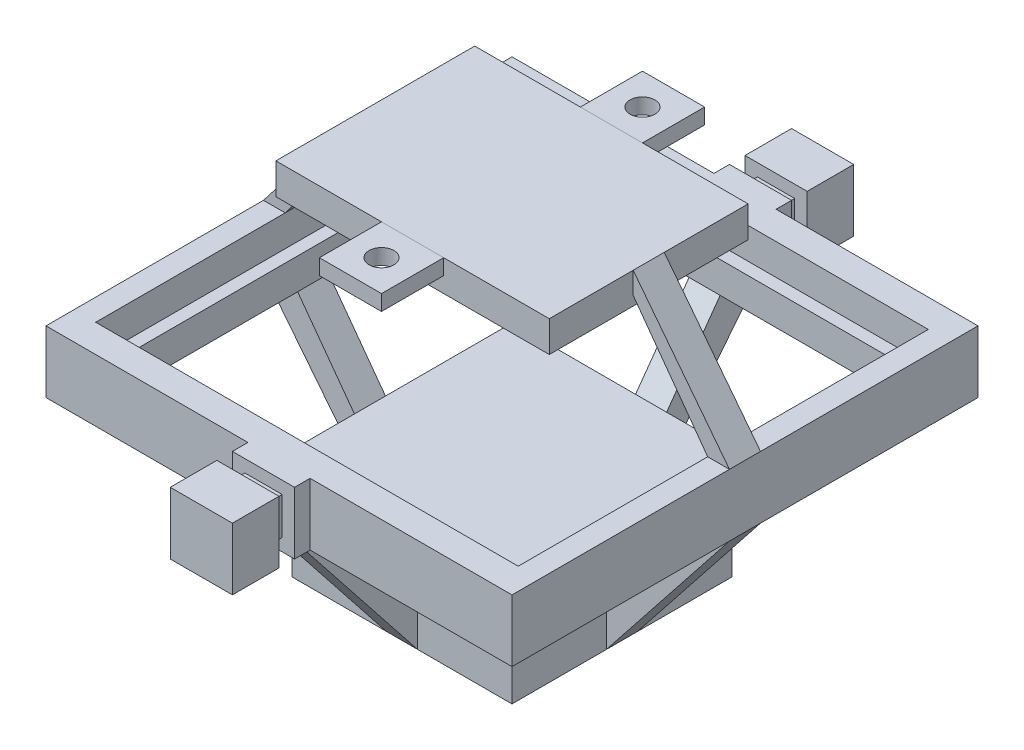
from build123d import *

# Parameters (mm, degrees)
SKETCH2_W              = 75
SKETCH2_H              = 75
BOSS_EXTRUDE1_DEPTH    = 5
SKETCH2_2_W            = 75
SKETCH2_2_H            = 75
BOSS_EXTRUDE2_DEPTH    = 5
SKETCH4_W              = 68
SKETCH4_H              = 66
CUT_EXTRUDE1_DEPTH     = 5
SKETCH5_W              = 64
SKETCH5_H              = 62
CUT_EXTRUDE2_DEPTH     = 5
SKETCH6_W              = 10
SKETCH6_H              = 10
BOSS_EXTRUDE3_DEPTH    = 2.5
SKETCH7_W              = 6
SKETCH7_H              = 6
BOSS_EXTRUDE4_DEPTH    = 2.5
SKETCH8_W              = 10
SKETCH8_H              = 10
BOSS_EXTRUDE5_DEPTH    = 7.5
SKETCH9_W              = 10
SKETCH9_H              = 10
BOSS_EXTRUDE6_DEPTH    = 2.5
SKETCH10_W             = 6
SKETCH10_H             = 6
BOSS_EXTRUDE7_DEPTH    = 2.5
SKETCH11_W             = 10
SKETCH11_H             = 10
BOSS_EXTRUDE8_DEPTH    = 7.5
SKETCH12_W             = 35.4
SKETCH12_H             = 35.4
BOSS_EXTRUDE9_DEPTH    = 17.7
SKETCH13_W             = 25.4
SKETCH13_H             = 25.4
CUT_EXTRUDE3_DEPTH     = 12.7
SKETCH14_W             = 44
SKETCH14_H             = 32
BOSS_EXTRUDE10_DEPTH   = 5
BOSS_EXTRUDE11_DEPTH   = 2.5
BOSS_EXTRUDE12_DEPTH   = 2.5
BOSS_EXTRUDE13_DEPTH   = 2.5
BOSS_EXTRUDE14_DEPTH   = 2.5
BOSS_EXTRUDE21_DEPTH   = 2.5
BOSS_EXTRUDE22_DEPTH   = 2.5
BOSS_EXTRUDE23_DEPTH   = 2.5
BOSS_EXTRUDE24_DEPTH   = 2.5
SKETCH22_W             = 10
SKETCH22_H             = 10
BOSS_EXTRUDE25_DEPTH   = 2.5
BOSS_EXTRUDE25_2_DEPTH = 2.5
SKETCH23_R             = 2
CUT_EXTRUDE4_DEPTH     = 2.5


with BuildPart() as part:
    # Sketch2 → Boss-Extrude1 (new body)
    with BuildSketch(Plane(origin=(0, 0, 0), x_dir=(1, 0, 0), z_dir=(0, 1, 0))):
        Rectangle(SKETCH2_W, SKETCH2_H)
    extrude(amount=BOSS_EXTRUDE1_DEPTH)

    # Sketch2_2 → Boss-Extrude2 (add)
    with BuildSketch(Plane(origin=(0, 0, 0), x_dir=(1, 0, 0), z_dir=(0, 1, 0))):
        Rectangle(SKETCH2_2_W, SKETCH2_2_H)
    extrude(amount=-BOSS_EXTRUDE2_DEPTH)

    # Sketch4 → Cut-Extrude1 (cut)
    with BuildSketch(Plane(origin=(0, 5, 0), x_dir=(1, 0, 0), z_dir=(0, 1, 0))):
        Rectangle(SKETCH4_W, SKETCH4_H)
    extrude(amount=-CUT_EXTRUDE1_DEPTH, mode=Mode.SUBTRACT)

    # Sketch5 → Cut-Extrude2 (cut)
    with BuildSketch(Plane(origin=(0, 0, 0), x_dir=(1, 0, 0), z_dir=(0, 1, 0))):
        Rectangle(SKETCH5_W, SKETCH5_H)
    extrude(amount=-CUT_EXTRUDE2_DEPTH, mode=Mode.SUBTRACT)

    # Sketch6 → Boss-Extrude3 (add)
    with BuildSketch(Plane.XY.offset(37.5)):
        Rectangle(SKETCH6_W, SKETCH6_H)
    extrude(amount=BOSS_EXTRUDE3_DEPTH)

    # Sketch7 → Boss-Extrude4 (add)
    with BuildSketch(Plane.XY.offset(40)):
        Rectangle(SKETCH7_W, SKETCH7_H)
    extrude(amount=BOSS_EXTRUDE4_DEPTH)

    # Sketch8 → Boss-Extrude5 (add)
    with BuildSketch(Plane.XY.offset(42.5)):
        Rectangle(SKETCH8_W, SKETCH8_H)
    extrude(amount=BOSS_EXTRUDE5_DEPTH)

    # Sketch9 → Boss-Extrude6 (add)
    with BuildSketch(Plane(origin=(0, 0, -37.5), x_dir=(-1, 0, 0), z_dir=(0, 0, -1))):
        Rectangle(SKETCH9_W, SKETCH9_H)
    extrude(amount=BOSS_EXTRUDE6_DEPTH)

    # Sketch10 → Boss-Extrude7 (add)
    with BuildSketch(Plane(origin=(0, 0, -40), x_dir=(-1, 0, 0), z_dir=(0, 0, -1))):
        Rectangle(SKETCH10_W, SKETCH10_H)
    extrude(amount=BOSS_EXTRUDE7_DEPTH)

    # Sketch11 → Boss-Extrude8 (add)
    with BuildSketch(Plane(origin=(0, 0, -42.5), x_dir=(-1, 0, 0), z_dir=(0, 0, -1))):
        Rectangle(SKETCH11_W, SKETCH11_H)
    extrude(amount=BOSS_EXTRUDE8_DEPTH)



with BuildPart() as body_2:
    # Sketch12 → Boss-Extrude9 (new body)
    with BuildSketch(Plane(origin=(0, -30, 0), x_dir=(1, 0, 0), z_dir=(0, 1, 0))):
        Rectangle(SKETCH12_W, SKETCH12_H)
    extrude(amount=BOSS_EXTRUDE9_DEPTH)

    # Sketch13 → Cut-Extrude3 (cut)
    with BuildSketch(Plane.XZ.offset(30)):
        Rectangle(SKETCH13_W, SKETCH13_H)
    extrude(amount=-CUT_EXTRUDE3_DEPTH, mode=Mode.SUBTRACT)


with BuildPart() as body_3:
    # Sketch14 → Boss-Extrude10 (new body)
    with BuildSketch(Plane(origin=(0, 25, 0), x_dir=(1, 0, 0), z_dir=(0, 1, 0))):
        Rectangle(SKETCH14_W, SKETCH14_H)
    extrude(amount=-BOSS_EXTRUDE10_DEPTH)


with BuildPart() as part_1:
    add(part.part)

    add(body_2.part)  # Boss-Extrude11 merges body 2
    # Sketch15 → Boss-Extrude11 (add)
    with BuildSketch(Plane.XY):
        Polygon((17.7, -30), (37.5, -5), (32, -5), (17.7, -24.5), align=None)
    extrude(amount=BOSS_EXTRUDE11_DEPTH)

    # Sketch15_2 → Boss-Extrude12 (add)
    with BuildSketch(Plane.XY):
        Polygon((17.7, -30), (37.5, -5), (32, -5), (17.7, -24.5), align=None)
    extrude(amount=-BOSS_EXTRUDE12_DEPTH)

    # Sketch17 → Boss-Extrude13 (add)
    with BuildSketch(Plane.XY):
        Polygon((-37.5, -5), (-17.7, -30), (-17.7, -24.5), (-32, -5), align=None)
    extrude(amount=BOSS_EXTRUDE13_DEPTH)

    # Sketch17_2 → Boss-Extrude14 (add)
    with BuildSketch(Plane.XY):
        Polygon((-37.5, -5), (-17.7, -30), (-17.7, -24.5), (-32, -5), align=None)
    extrude(amount=-BOSS_EXTRUDE14_DEPTH)


    add(body_3.part)  # Boss-Extrude21 merges body 3
    # Sketch21 → Boss-Extrude21 (add)
    with BuildSketch(Plane.XY):
        Polygon((-22, 25), (-37.5, 5), (-34, 5), (-22, 21.5), align=None)
        Polygon((37.5, 5), (22, 25), (22, 21.5), (34, 5), align=None)
    extrude(amount=BOSS_EXTRUDE21_DEPTH)

    # Sketch21_2 → Boss-Extrude22 (add)
    with BuildSketch(Plane.XY):
        Polygon((-22, 25), (-37.5, 5), (-34, 5), (-22, 21.5), align=None)
        Polygon((37.5, 5), (22, 25), (22, 21.5), (34, 5), align=None)
    extrude(amount=-BOSS_EXTRUDE22_DEPTH)

    # Sketch20 → Boss-Extrude23 (add)
    with BuildSketch(Plane(origin=(0, 0, 0), x_dir=(0, 0, -1), z_dir=(1, 0, 0))):
        Polygon((-37.5, -5), (-17.7, -30), (-17.7, -23.5), (-31, -5), align=None)
        Polygon((17.7, -30), (37.5, -5), (31, -5), (17.7, -23.5), align=None)
    extrude(amount=BOSS_EXTRUDE23_DEPTH)

    # Sketch20_3 → Boss-Extrude24 (add)
    with BuildSketch(Plane(origin=(0, 0, 0), x_dir=(0, 0, -1), z_dir=(1, 0, 0))):
        Polygon((-37.5, -5), (-17.7, -30), (-17.7, -23.5), (-31, -5), align=None)
        Polygon((17.7, -30), (37.5, -5), (31, -5), (17.7, -23.5), align=None)
    extrude(amount=-BOSS_EXTRUDE24_DEPTH)


with BuildPart() as body_2_2:
    # Sketch22 → Boss-Extrude25 (new body)
    with BuildSketch(Plane(origin=(0, 25, 0), x_dir=(1, 0, 0), z_dir=(0, 1, 0))):
        with Locations((0, 21)):
            Rectangle(SKETCH22_W, SKETCH22_H)
    extrude(amount=-BOSS_EXTRUDE25_DEPTH)


with BuildPart() as body_3_2:
    # Sketch22 → Boss-Extrude25 2 (new body)
    with BuildSketch(Plane(origin=(0, 25, 0), x_dir=(1, 0, 0), z_dir=(0, 1, 0))):
        with Locations((0, -21)):
            Rectangle(SKETCH22_W, SKETCH22_H)
    extrude(amount=-BOSS_EXTRUDE25_2_DEPTH)


with BuildPart() as cut_extrude4_tool:
    # Sketch23 → Cut-Extrude4 (new body)
    with BuildSketch(Plane(origin=(0, 25, 0), x_dir=(1, 0, 0), z_dir=(0, 1, 0))):
        with Locations((0, 21)):
            Circle(SKETCH23_R)
        with Locations((0, -21)):
            Circle(SKETCH23_R)
    extrude(amount=-CUT_EXTRUDE4_DEPTH)


with BuildPart() as body_2_2_1:
    add(body_2_2.part)

    # Cut-Extrude4: cut by cut_extrude4_tool
    add(cut_extrude4_tool.part, mode=Mode.SUBTRACT)


with BuildPart() as body_3_2_1:
    add(body_3_2.part)

    # Cut-Extrude4: cut by cut_extrude4_tool
    add(cut_extrude4_tool.part, mode=Mode.SUBTRACT)


solid = Compound([part_1.part, body_2_2_1.part, body_3_2_1.part])
